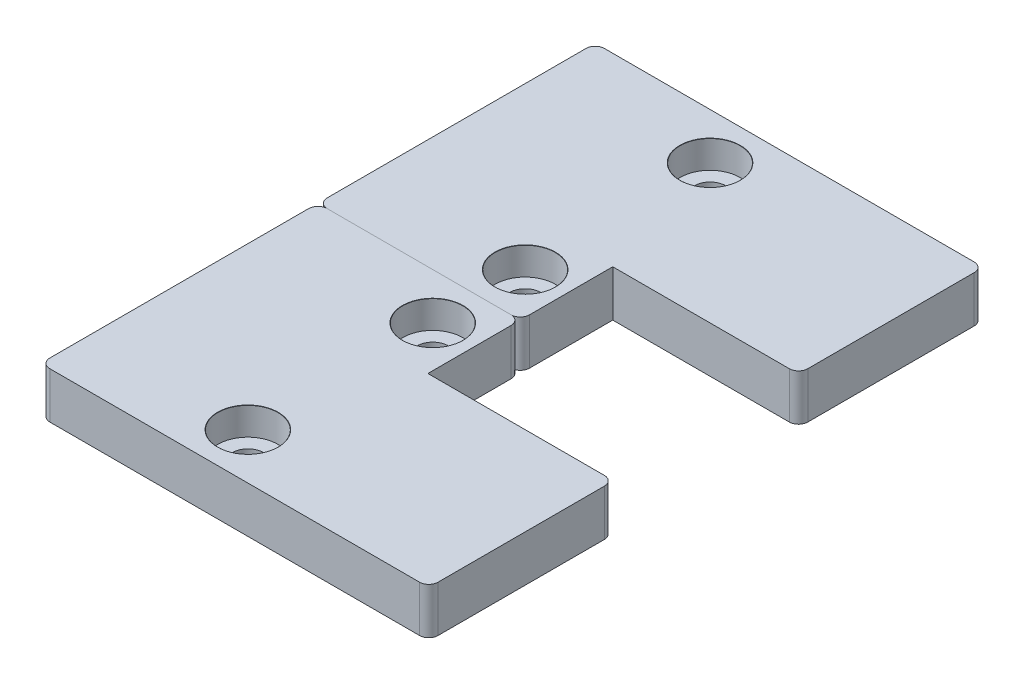
from build123d import *

# Parameters (mm, degrees)
SKETCH1_W                     = 42
SKETCH1_H                     = 20
BOSS_EXTRUDE1_DEPTH           = 5
SKETCH2_W                     = 21.9
SKETCH2_H                     = 10
BOSS_EXTRUDE2_DEPTH           = 5
CBORE_FOR_M3_SHCS1_AT_2_COUNT = 2
CBORE_FOR_M3_SHCS1_AT_2_PITCH = 20
FILLET1_R                     = 1


with BuildPart() as part:
    # Sketch1 → Boss-Extrude1 (new body)
    with BuildSketch(Plane(origin=(0, 0, 0), x_dir=(1, 0, 0), z_dir=(0, 1, 0))):
        Rectangle(SKETCH1_W, SKETCH1_H)
    extrude(amount=BOSS_EXTRUDE1_DEPTH)

    # Sketch2 → Boss-Extrude2 (add)
    with BuildSketch(Plane(origin=(0, 5, 0), x_dir=(1, 0, 0), z_dir=(0, 1, 0))):
        with Locations((-10.05, 15)):
            Rectangle(SKETCH2_W, SKETCH2_H)
    extrude(amount=-BOSS_EXTRUDE2_DEPTH)

    # Sketch7 → CBORE for M3 SHCS1 (revolve, cut)
    with BuildSketch(Plane(origin=(-3.575, 5, -15), x_dir=(0, 0, 1), z_dir=(1, 0, 0))):
        Polygon((0, 0), (0, 5), (1.7, 5), (1.7, 3), (3.25, 3), (3.25, 0.020977491), (3.275, 0), align=None)
    cbore_for_m3_shcs1 = revolve(axis=Axis((-3.575, 11.35, -15), (0, -1, 0)), mode=Mode.SUBTRACT)

    # CBORE for M3 SHCS1 at 2: CBORE for M3 SHCS1 ×2
    with Locations(*[(0, 0, i * CBORE_FOR_M3_SHCS1_AT_2_PITCH) for i in range(1, CBORE_FOR_M3_SHCS1_AT_2_COUNT)]):
        add(cbore_for_m3_shcs1, mode=Mode.SUBTRACT)

    # Fillet1
    fillet1_edges = [part.edges().sort_by_distance(p)[0] for p in [
        (-21, 2.5, -20),
        (0.9, 2.5, -20),
        (21, 2.5, -10),
        (21, 2.5, 10),
        (-21, 2.5, 10),
    ]]
    fillet(fillet1_edges, radius=FILLET1_R)


with BuildPart() as body_2:
    # Mirror1: mirrored copy
    add(part.part.mirror(Plane(origin=(-21, 0, -20), x_dir=(1, 0, 0), z_dir=(0, 0, -1))))


solid = Compound([part.part, body_2.part])
